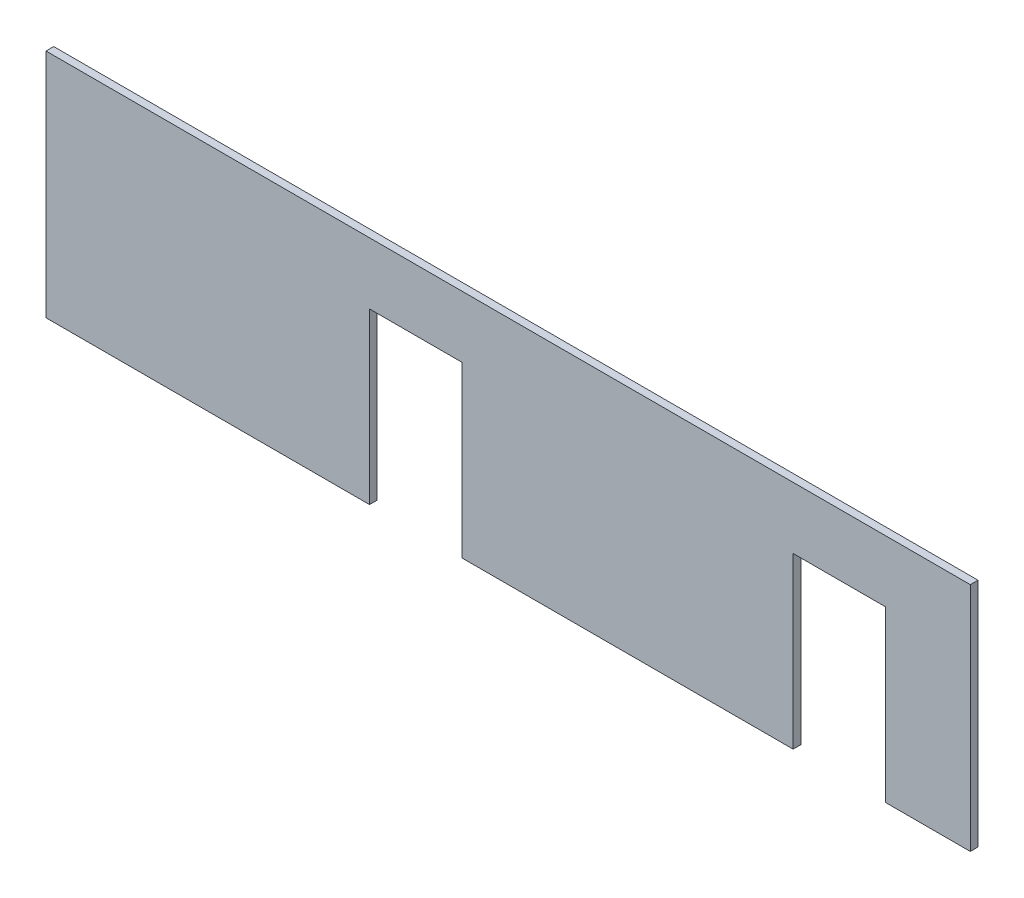
from build123d import *

# Parameters (mm, degrees)
BOSS_EXTRUDE1_DEPTH = 5


with BuildPart() as part:
    # Sketch1 → Boss-Extrude1 (new body)
    with BuildSketch(Plane.XY):
        Polygon((-300, 75), (300, 75), (300, -75), (245, -75), (245, 35), (185, 35), (185, -75), (-30, -75), (-30, 35), (-90, 35), (-90, -75), (-300, -75), align=None)
    extrude(amount=BOSS_EXTRUDE1_DEPTH)


solid = part.part
